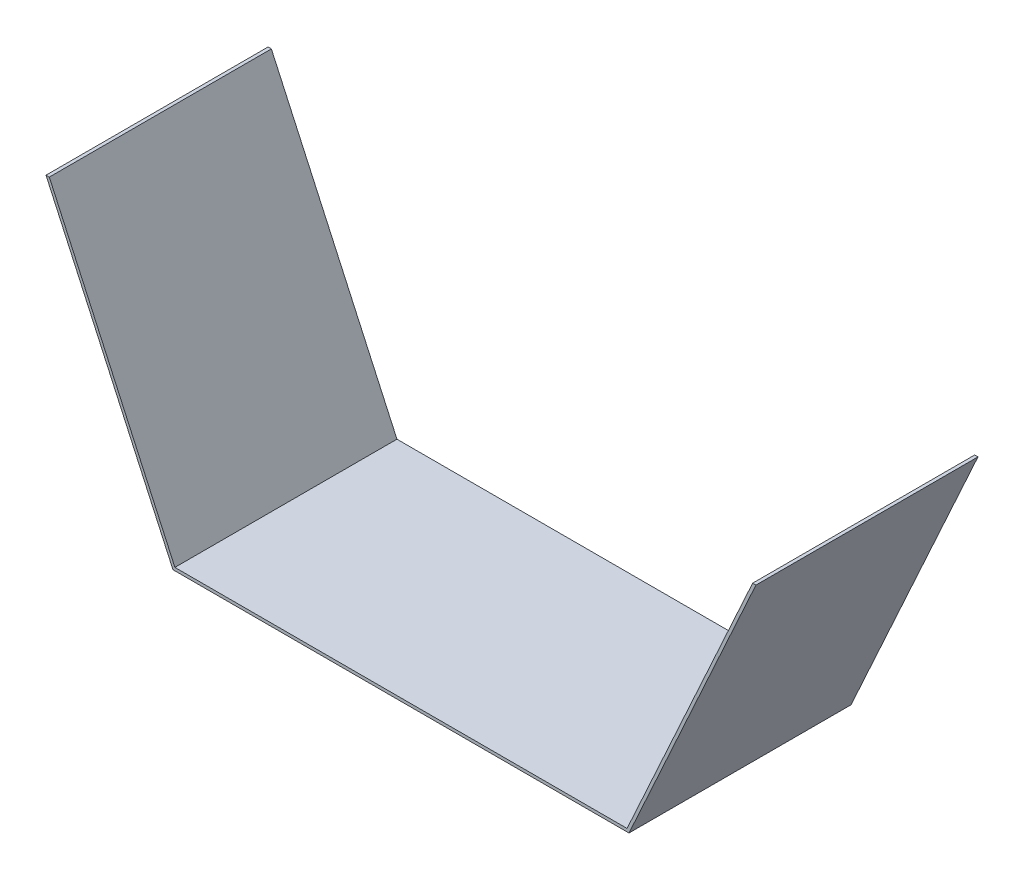
from build123d import *

# Parameters (mm, degrees)
BOSS_EXTRUDE1_DEPTH = 112.268


with BuildPart() as part:
    # Sketch1 → Boss-Extrude1 (new body)
    with BuildSketch(Plane.XY):
        Polygon((-114.3, -177.8), (114.3, -177.8), (177.8, -38.652173913), (179.469606508, -38.652173913), (115.276448571, -179.31892), (-115.276448571, -179.31892), (-179.469606508, -38.652173913), (-177.8, -38.652173913), align=None)
    extrude(amount=BOSS_EXTRUDE1_DEPTH)


solid = part.part
